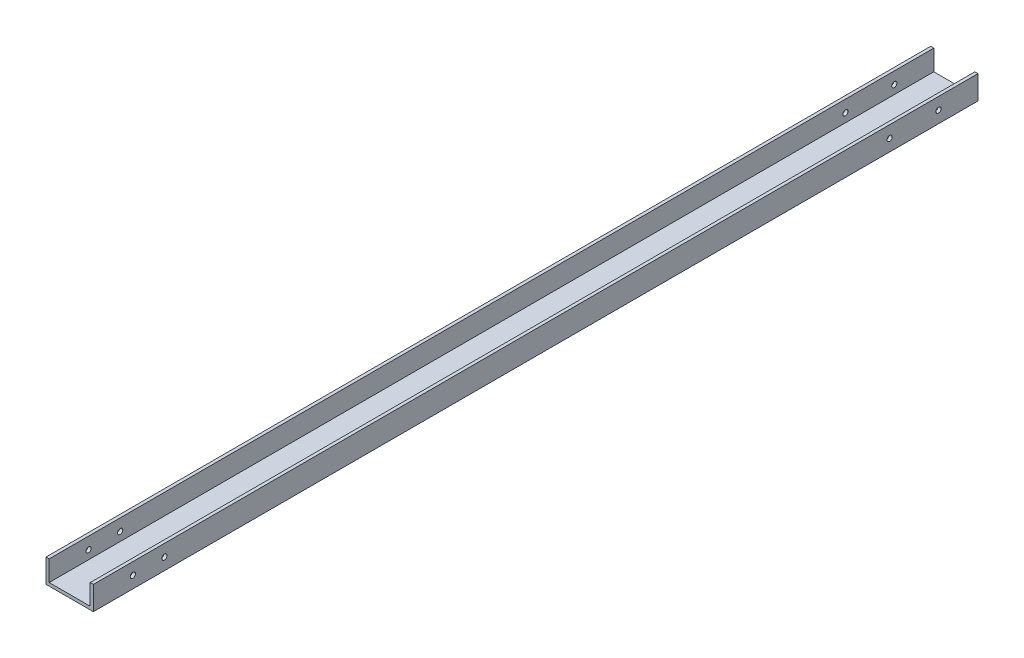
from build123d import *

# Parameters (mm, degrees)
EXTRUDE_1_DEPTH = 560.3
M4X0_7_1_D      = 3.3
M4X0_7_1_DEPTH  = 11.5
M4X0_7_1_TIP    = 0.991420021
M4X0_7_2_D      = 3.3
M4X0_7_2_DEPTH  = 11.5
M4X0_7_2_TIP    = 0.991420021
M4X0_7_4_D      = 3.3
M4X0_7_4_DEPTH  = 11.5
M4X0_7_4_TIP    = 0.991420021


with BuildPart() as part:
    # ｽｹｯﾁ1 → ﾎﾞｽ - 押し出し1 (new body)
    with BuildSketch(Plane.XY):
        Polygon((0, 0), (15, 0), (15, 15), (13, 15), (13, 2), (-13, 2), (-13, 15), (-15, 15), (-15, 0), align=None)
    extrude(amount=EXTRUDE_1_DEPTH)

    # M4x0.7 ねじ穴1
    with Locations(Plane(origin=(15, 7.5, 56), x_dir=(0, 0, 1), z_dir=(1, 0, 0))):
        with Locations((0, 0), (-31, 0)):
            Hole(M4X0_7_1_D / 2, depth=M4X0_7_1_DEPTH)
            with Locations((0, 0, -(M4X0_7_1_DEPTH + M4X0_7_1_TIP / 2))):  # 118° drill point
                Cone(0, M4X0_7_1_D / 2, M4X0_7_1_TIP, mode=Mode.SUBTRACT)

    # M4x0.7 ねじ穴2
    with Locations(Plane(origin=(15, 7.5, 535.3), x_dir=(0, 0, 1), z_dir=(1, 0, 0))):
        with Locations((0, 0), (-20, 0)):
            Hole(M4X0_7_2_D / 2, depth=M4X0_7_2_DEPTH)
            with Locations((0, 0, -(M4X0_7_2_DEPTH + M4X0_7_2_TIP / 2))):  # 118° drill point
                Cone(0, M4X0_7_2_D / 2, M4X0_7_2_TIP, mode=Mode.SUBTRACT)

    # M4x0.7 ねじ穴4
    with Locations(Plane(origin=(-15, 7.5, 56), x_dir=(0, 0, -1), z_dir=(-1, 0, 0))):
        with Locations((0, 0), (31, 0), (-459.3, 0), (-479.3, 0)):
            Hole(M4X0_7_4_D / 2, depth=M4X0_7_4_DEPTH)
            with Locations((0, 0, -(M4X0_7_4_DEPTH + M4X0_7_4_TIP / 2))):  # 118° drill point
                Cone(0, M4X0_7_4_D / 2, M4X0_7_4_TIP, mode=Mode.SUBTRACT)


solid = part.part
